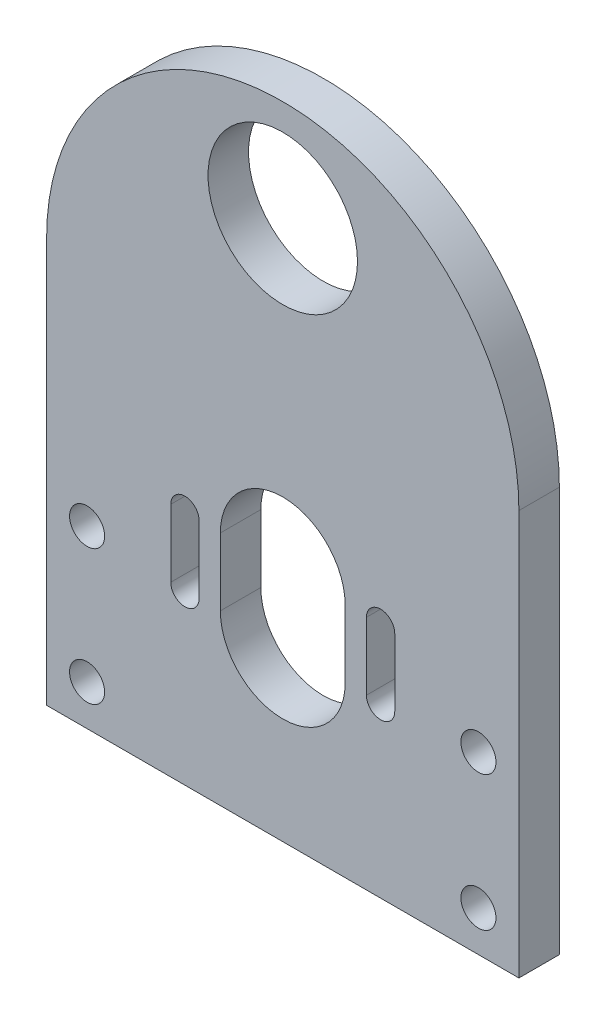
from build123d import *

# Parameters (mm, degrees)
IZIM1_R                     = 11.075
IZIM1_R_2                   = 2.6
Y_KSEKLIK_EKSTR_ZYON2_DEPTH = 6


with BuildPart() as part:
    # Çizim1 → Yükseklik-Ekstrüzyon2 (new body)
    with BuildSketch(Plane.XY):
        with BuildLine():
            Line((-56.410377678, 29.652139902), (-56.410377678, -30.347860098))
            Line((-56.410377678, -30.347860098), (13.589622322, -30.347860098))
            Line((13.589622322, -30.347860098), (13.589622322, 29.652139902))
            ThreePointArc((13.589622322, 29.652139902), (-21.410377678, 64.652139902), (-56.410377678, 29.652139902))
        make_face()
        with Locations((-21.410377678, 49.652139902)):
            Circle(IZIM1_R, mode=Mode.SUBTRACT)
        with Locations((-50.410377678, -24.347860098)):
            Circle(IZIM1_R_2, mode=Mode.SUBTRACT)
        with Locations((7.589622322, -24.347860098)):
            Circle(IZIM1_R_2, mode=Mode.SUBTRACT)
        with Locations((-50.410377678, -4.347860098)):
            Circle(IZIM1_R_2, mode=Mode.SUBTRACT)
        with Locations((7.589622322, -4.347860098)):
            Circle(IZIM1_R_2, mode=Mode.SUBTRACT)
        with BuildLine():
            Line((-12.160377678, 4.652139902), (-12.160377678, -5.347860098))
            ThreePointArc((-12.160377678, -5.347860098), (-21.410377678, -14.597860098), (-30.660377678, -5.347860098))
            Line((-30.660377678, -5.347860098), (-30.660377678, 4.652139902))
            ThreePointArc((-30.660377678, 4.652139902), (-21.410377678, 13.902139902), (-12.160377678, 4.652139902))
        make_face(mode=Mode.SUBTRACT)
        with BuildLine():
            Line((-33.810377678, 4.652139902), (-33.810377678, -5.347860098))
            ThreePointArc((-33.810377678, -5.347860098), (-35.910377678, -7.447860098), (-38.010377678, -5.347860098))
            Line((-38.010377678, -5.347860098), (-38.010377678, 4.652139902))
            ThreePointArc((-38.010377678, 4.652139902), (-35.910377678, 6.752139902), (-33.810377678, 4.652139902))
        make_face(mode=Mode.SUBTRACT)
        with BuildLine():
            Line((-4.810377678, 4.652139902), (-4.810377678, -5.347860098))
            ThreePointArc((-4.810377678, -5.347860098), (-6.910377678, -7.447860098), (-9.010377678, -5.347860098))
            Line((-9.010377678, -5.347860098), (-9.010377678, 4.652139902))
            ThreePointArc((-9.010377678, 4.652139902), (-6.910377678, 6.752139902), (-4.810377678, 4.652139902))
        make_face(mode=Mode.SUBTRACT)
    extrude(amount=Y_KSEKLIK_EKSTR_ZYON2_DEPTH)


solid = part.part
